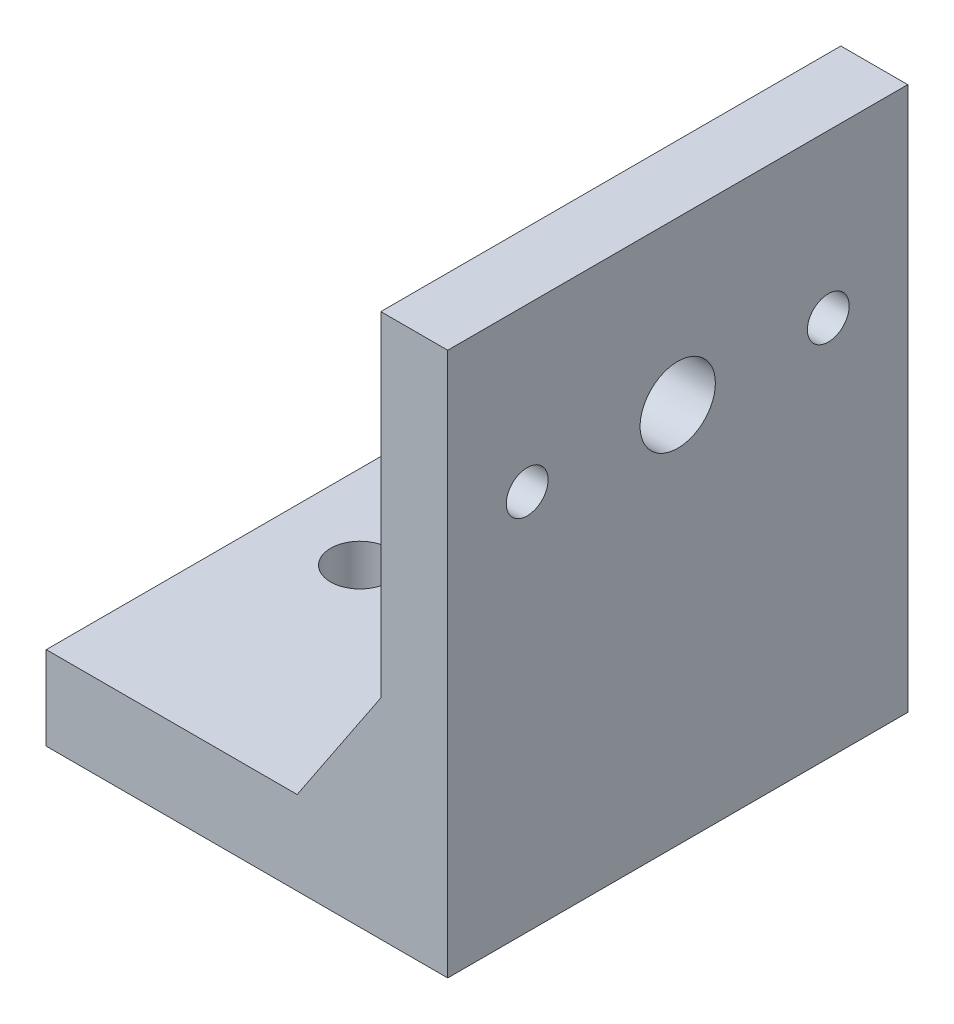
from build123d import *

# Parameters (mm, degrees)
SKETCH1_W           = 48
SKETCH1_H           = 55
BOSS_EXTRUDE1_DEPTH = 10
SKETCH2_W           = 8
SKETCH2_H           = 55
BOSS_EXTRUDE2_DEPTH = 65
SKETCH3_R           = 4.5
CUT_EXTRUDE1_DEPTH  = 65
SKETCH4_R           = 2.5
CUT_EXTRUDE2_DEPTH  = 65
SKETCH5_R           = 3.5
CUT_EXTRUDE4_DEPTH  = 65
BOSS_EXTRUDE3_DEPTH = 5


with BuildPart() as part:
    # Sketch1 → Boss-Extrude1 (new body)
    with BuildSketch(Plane(origin=(0, 0, 0), x_dir=(1, 0, 0), z_dir=(0, 1, 0))):
        Rectangle(SKETCH1_W, SKETCH1_H)
    extrude(amount=BOSS_EXTRUDE1_DEPTH)

    # Sketch2 → Boss-Extrude2 (add)
    with BuildSketch(Plane(origin=(0, 0, 0), x_dir=(1, 0, 0), z_dir=(0, 1, 0))):
        with Locations((20, 0)):
            Rectangle(SKETCH2_W, SKETCH2_H)
    extrude(amount=BOSS_EXTRUDE2_DEPTH)

    # Sketch3 → Cut-Extrude1 (cut)
    with BuildSketch(Plane(origin=(24, 0, 0), x_dir=(0, 0, -1), z_dir=(1, 0, 0))):
        with Locations((0, 45.6)):
            Circle(SKETCH3_R)
    extrude(amount=-CUT_EXTRUDE1_DEPTH, mode=Mode.SUBTRACT)

    # Sketch4 → Cut-Extrude2 (cut)
    with BuildSketch(Plane(origin=(24, 0, 0), x_dir=(0, 0, -1), z_dir=(1, 0, 0))):
        with Locations((-18, 45.6)):
            Circle(SKETCH4_R)
        with Locations((18, 45.6)):
            Circle(SKETCH4_R)
    extrude(amount=-CUT_EXTRUDE2_DEPTH, mode=Mode.SUBTRACT)

    # Sketch5 → Cut-Extrude4 (cut)
    with BuildSketch(Plane(origin=(0, 0, 0), x_dir=(1, 0, 0), z_dir=(0, 1, 0))):
        with Locations((-14, 0)):
            Circle(SKETCH5_R)
        with Locations((4, 0)):
            Circle(SKETCH5_R)
    extrude(amount=CUT_EXTRUDE4_DEPTH, mode=Mode.SUBTRACT)

    # Sketch8 → Boss-Extrude3 (add)
    with BuildSketch(Plane(origin=(0, 0, -27.5), x_dir=(-1, 0, 0), z_dir=(0, 0, -1))):
        Polygon((-16, 25), (-16, 10), (-6, 10), align=None)
    boss_extrude3 = extrude(amount=-BOSS_EXTRUDE3_DEPTH)

    # Mirror1: Boss-Extrude3 across plane
    add(boss_extrude3.mirror(Plane.XY))


solid = part.part
